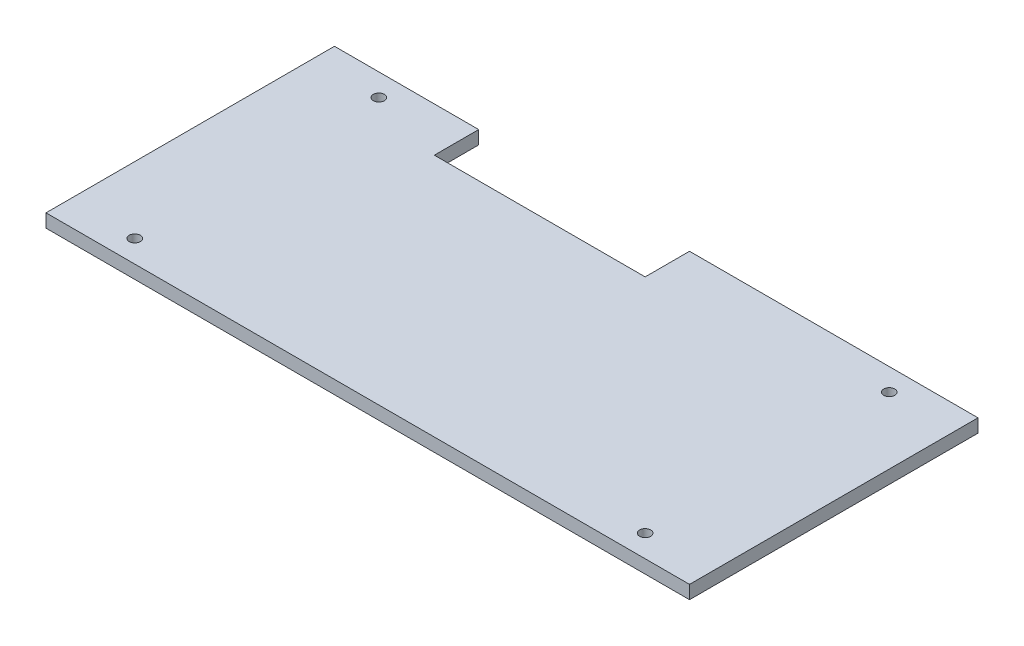
from build123d import *

# Parameters (mm, degrees)
SKETCH1_R           = 2.5
BOSS_EXTRUDE1_DEPTH = 6


with BuildPart() as part:
    # Sketch1 → Boss-Extrude1 (new body)
    with BuildSketch(Plane(origin=(0, 0, 0), x_dir=(1, 0, 0), z_dir=(0, 1, 0))):
        Polygon((-160, -65), (130, -65), (130, 65), (0, 65), (0, 45), (-95, 45), (-95, 65), (-160, 65), align=None)
        with Locations((-130, 55)):
            Circle(SKETCH1_R, mode=Mode.SUBTRACT)
        with Locations((100, 55)):
            Circle(SKETCH1_R, mode=Mode.SUBTRACT)
        with Locations((100, -55)):
            Circle(SKETCH1_R, mode=Mode.SUBTRACT)
        with Locations((-130, -55)):
            Circle(SKETCH1_R, mode=Mode.SUBTRACT)
    extrude(amount=BOSS_EXTRUDE1_DEPTH)


solid = part.part
